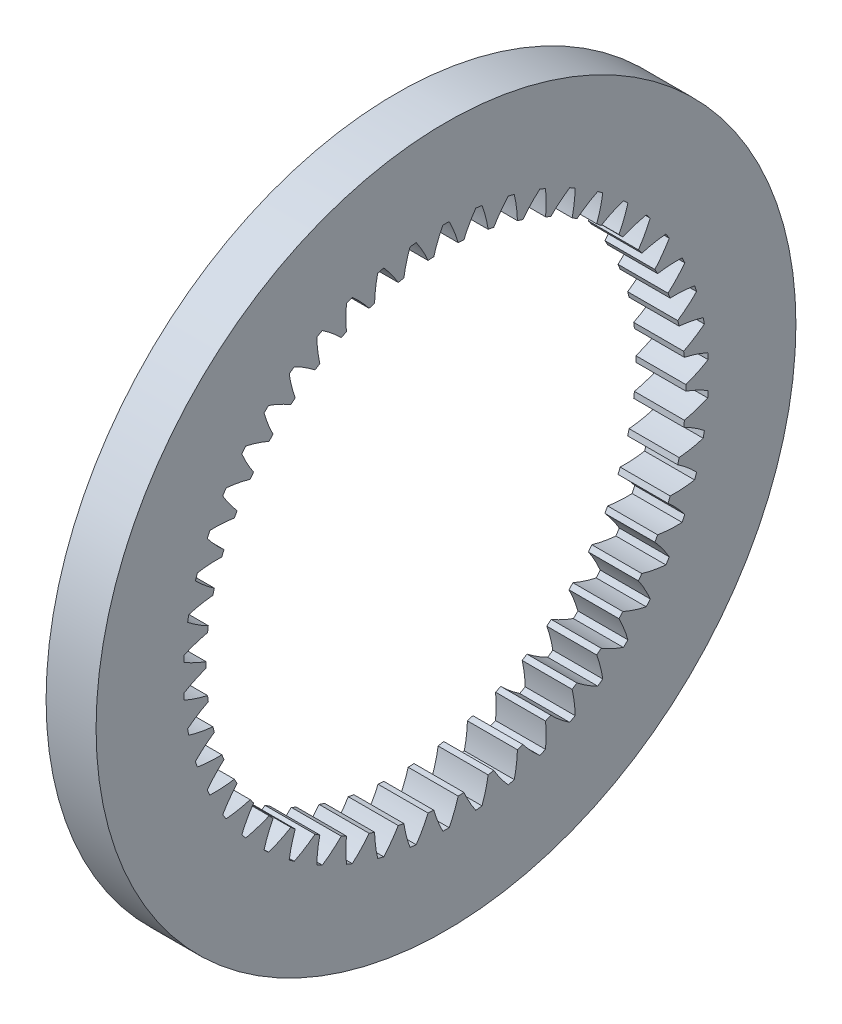
from build123d import *

# Parameters (mm, degrees)
BASPROSKE_W     = 5
BASPROSKE_H     = 11
TOOTHCUT_DEPTH  = 50.749371855
TEETHCUTS_COUNT = 50
TEETHCUTS_ANGLE = 352.8


with BuildPart() as part:
    # BasProSke → Base-Revolve (revolve)
    with BuildSketch(Plane(origin=(0, 0, 0), x_dir=(1, 0, 0), z_dir=(0, 1, 0))):
        with Locations((2.5, 29.5)):
            Rectangle(BASPROSKE_W, BASPROSKE_H)
    revolve(axis=Axis((-10, 0, 0), (1, 0, 0)))

    # TooCutSke → ToothCut (cut, through all)
    with BuildSketch(Plane(origin=(0, 0, 0), x_dir=(0, 0, -1), z_dir=(1, 0, 0))):
        with BuildLine():
            ThreePointArc((1.228249008, 23.943116955), (0.8277994, 25.118901547), (0.312635126, 26.249138277))
            ThreePointArc((0.312635126, 26.249138277), (0, 26.251), (-0.312635126, 26.249138277))
            ThreePointArc((-0.312635126, 26.249138277), (-0.8277994, 25.118901547), (-1.228249008, 23.943116955))
            ThreePointArc((-1.228249008, 23.943116955), (0, 23.9746), (1.228249008, 23.943116955))
        make_face()
    toothcut = extrude(amount=TOOTHCUT_DEPTH, mode=Mode.SUBTRACT)

    # TeethCuts: ToothCut ×50 about axis
    teethcuts_axis = Axis((-10, 0, 0), (1, 0, 0))
    for i in range(1, TEETHCUTS_COUNT):
        add(toothcut.rotate(teethcuts_axis, i * TEETHCUTS_ANGLE / (TEETHCUTS_COUNT - 1)), mode=Mode.SUBTRACT)


solid = part.part
